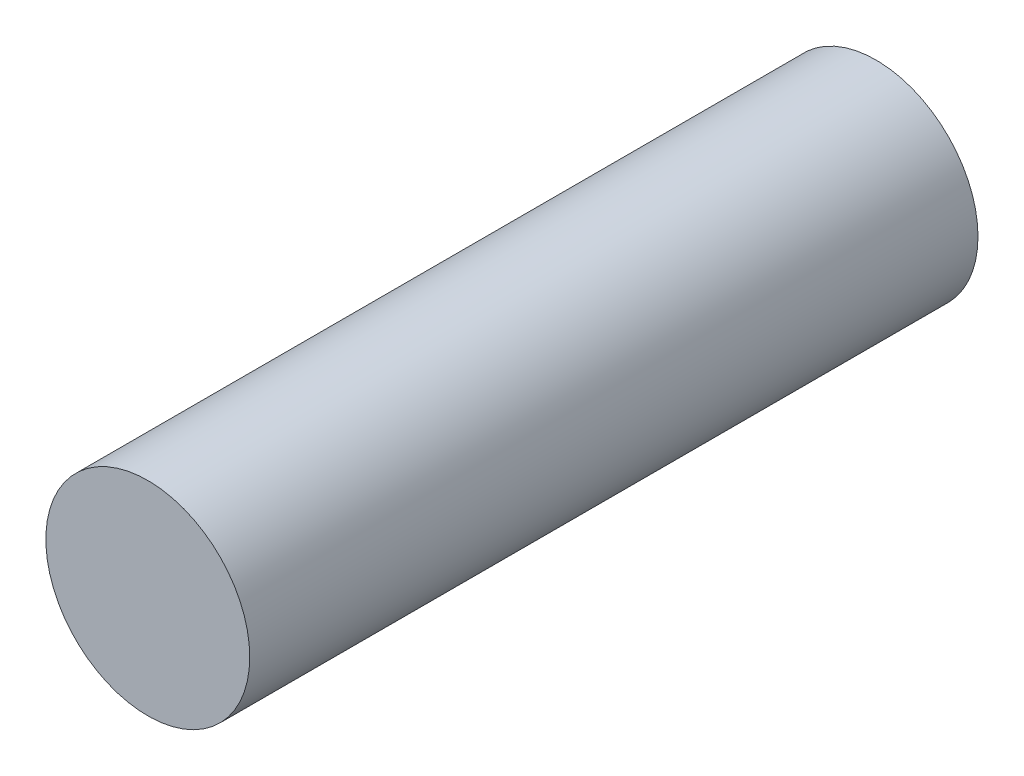
from build123d import *

# Parameters (mm, degrees)
SKIZZE1_R                       = 1.96
AUFSATZ_LINEAR_AUSTRAGEN1_DEPTH = 14


with BuildPart() as part:
    # Skizze1 → Aufsatz-Linear austragen1 (new body)
    with BuildSketch(Plane.XY):
        Circle(SKIZZE1_R)
    extrude(amount=AUFSATZ_LINEAR_AUSTRAGEN1_DEPTH)


solid = part.part
